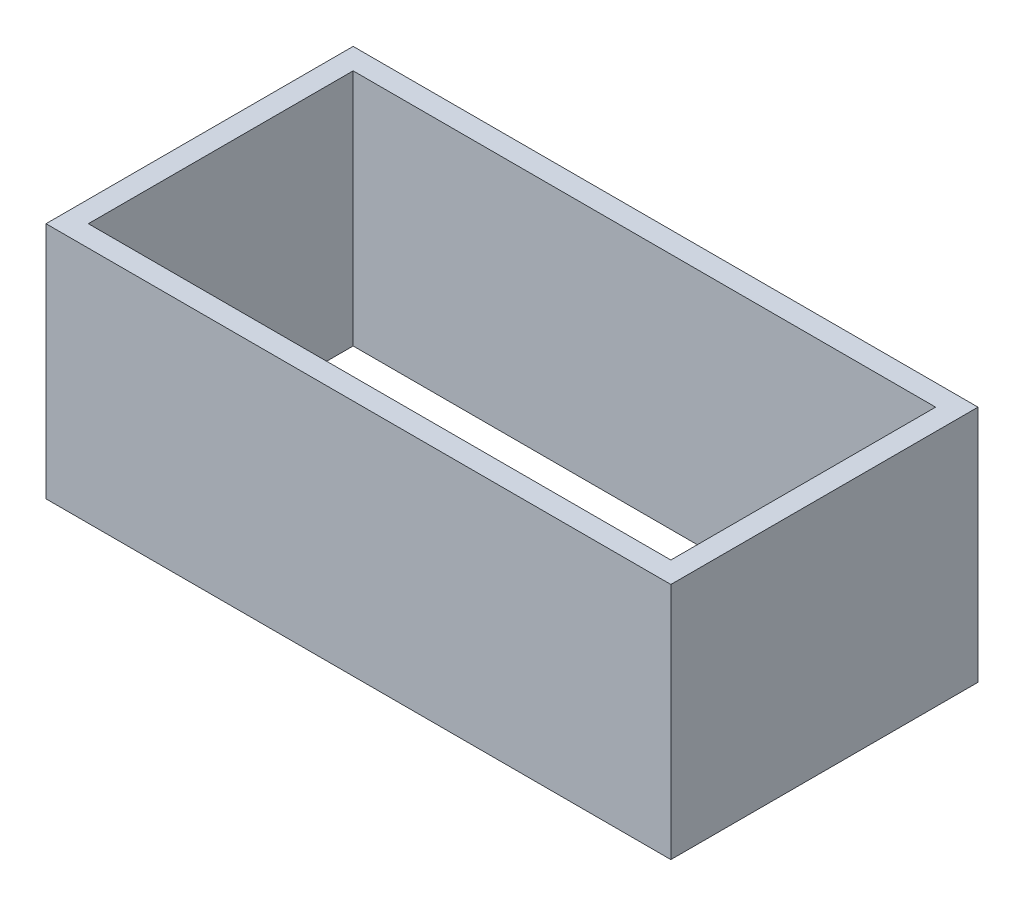
from build123d import *

# Parameters (mm, degrees)
SKETCH1_W           = 59
SKETCH1_H           = 29
SKETCH1_W_2         = 55
SKETCH1_H_2         = 25
BOSS_EXTRUDE1_DEPTH = 22.5


with BuildPart() as part:
    # Sketch1 → Boss-Extrude1 (new body)
    with BuildSketch(Plane(origin=(0, 0, 0), x_dir=(1, 0, 0), z_dir=(0, 1, 0))):
        Rectangle(SKETCH1_W, SKETCH1_H)
        Rectangle(SKETCH1_W_2, SKETCH1_H_2, mode=Mode.SUBTRACT)
    extrude(amount=BOSS_EXTRUDE1_DEPTH)


solid = part.part
